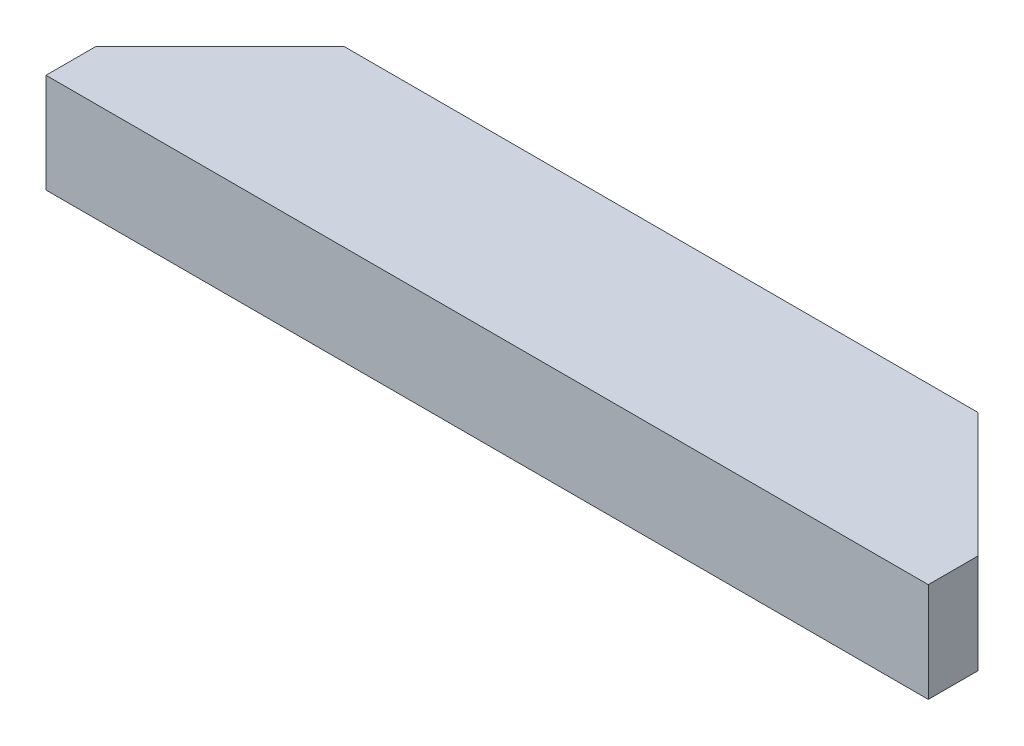
from build123d import *

# Parameters (mm, degrees)
SKETCH1_W           = 450.85
SKETCH1_H           = 88.9
BOSS_EXTRUDE1_DEPTH = 25.4
CUT_EXTRUDE1_DEPTH  = 51.8


with BuildPart() as part:
    # Sketch1 → Boss-Extrude1 (new body, symmetric)
    with BuildSketch(Plane(origin=(0, 0, 0), x_dir=(1, 0, 0), z_dir=(0, 1, 0))):
        Rectangle(SKETCH1_W, SKETCH1_H)
    extrude(amount=BOSS_EXTRUDE1_DEPTH, both=True)

    # Sketch2 → Cut-Extrude1 (cut, through all)
    with BuildSketch(Plane(origin=(0, 25.4, 0), x_dir=(1, 0, 0), z_dir=(0, 1, 0))):
        Polygon((-225.425, 44.45), (-225.425, -19.05), (-161.925, 44.45), align=None)
        Polygon((225.425, -19.05), (161.925, 44.45), (225.425, 44.45), align=None)
    extrude(amount=-CUT_EXTRUDE1_DEPTH, mode=Mode.SUBTRACT)


solid = part.part
